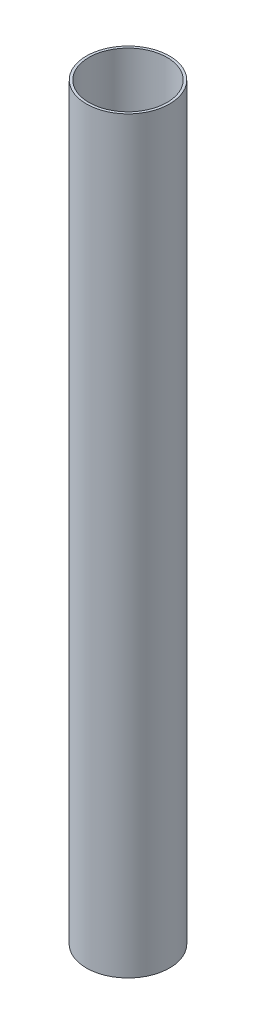
from build123d import *

# Parameters (mm, degrees)
SKETCH1_R           = 6.35
SKETCH1_R_2         = 5.969
BOSS_EXTRUDE1_DEPTH = 114.3


with BuildPart() as part:
    # Sketch1 → Boss-Extrude1 (new body)
    with BuildSketch(Plane(origin=(0, 0, 0), x_dir=(1, 0, 0), z_dir=(0, 1, 0))):
        Circle(SKETCH1_R)
        Circle(SKETCH1_R_2, mode=Mode.SUBTRACT)
    extrude(amount=BOSS_EXTRUDE1_DEPTH)


solid = part.part
